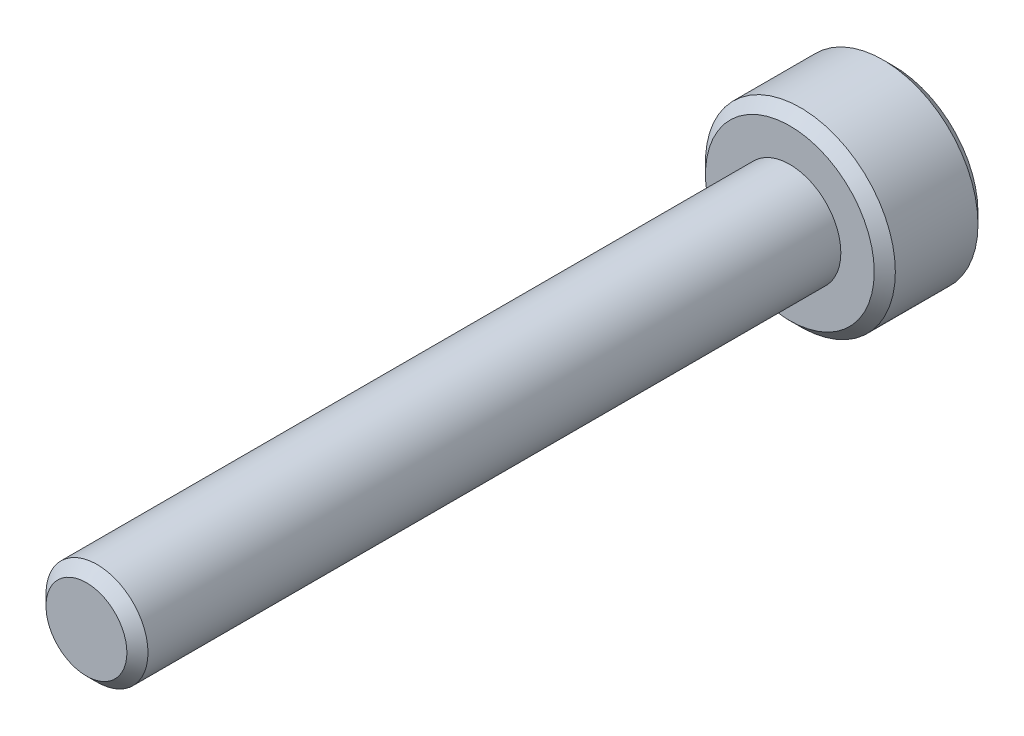
from build123d import *

# Parameters (mm, degrees)
SKIZZE1_R                       = 2.7
AUFSATZ_LINEAR_AUSTRAGEN1_DEPTH = 2.95
SKIZZE2_R                       = 1.45
AUFSATZ_LINEAR_AUSTRAGEN2_DEPTH = 20
FASE1_SIZE                      = 0.3
SCHNITT_LINEAR_AUSTRAGEN1_DEPTH = 2.5


with BuildPart() as part:
    # Skizze1 → Aufsatz-Linear austragen1 (new body)
    with BuildSketch(Plane.XY):
        Circle(SKIZZE1_R)
    extrude(amount=AUFSATZ_LINEAR_AUSTRAGEN1_DEPTH)

    # Skizze2 → Aufsatz-Linear austragen2 (add)
    with BuildSketch(Plane.XY.offset(2.95)):
        Circle(SKIZZE2_R)
    extrude(amount=AUFSATZ_LINEAR_AUSTRAGEN2_DEPTH)

    # Fase1
    fase1_edges = [part.edges().sort_by_distance(p)[0] for p in [
        (-2.7, 0, 0),
        (-2.7, 0, 2.95),
        (-1.45, 0, 22.95),
    ]]
    chamfer(fase1_edges, length=FASE1_SIZE)

    # Skizze3 → Schnitt-Linear austragen1 (cut)
    with BuildSketch(Plane(origin=(0, 0, 0), x_dir=(-1, 0, 0), z_dir=(0, 0, -1))):
        Polygon((1.25, 0.721687836), (0, 1.443375673), (-1.25, 0.721687836), (-1.25, -0.721687836), (0, -1.443375673), (1.25, -0.721687836), align=None)
    extrude(amount=-SCHNITT_LINEAR_AUSTRAGEN1_DEPTH, mode=Mode.SUBTRACT)


solid = part.part
